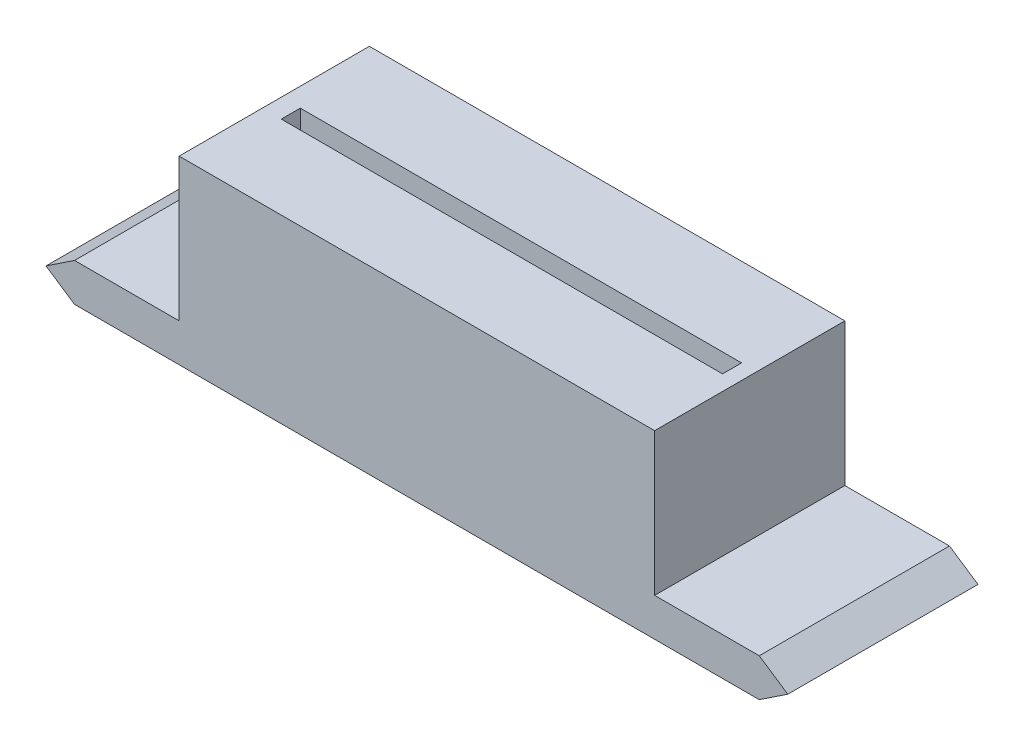
from build123d import *

# Parameters (mm, degrees)
P_IDAT_VYSUNUT_M1_DEPTH  = 10
SKICA2_R                 = 3
ODEBRAT_VYSUNUT_M1_DEPTH = 1
SKICA3_R                 = 2.6
ODEBRAT_VYSUNUT_M2_DEPTH = 7.5
SKICA4_W                 = 23.2
SKICA4_H                 = 1
ODEBRAT_VYSUNUT_M3_DEPTH = 1


with BuildPart() as part:
    # Skica1 → Přidat vysunutím1 (new body)
    with BuildSketch(Plane.XY):
        Polygon((-52.156744291, -7.714704976), (-16.156744291, -7.714704976), (-14.656744291, -6.714704976), (-16.156744291, -5.714704976), (-21.656744291, -5.714704976), (-21.656744291, 1.785295024), (-46.656744291, 1.785295024), (-46.656744291, -5.714704976), (-52.156744291, -5.714704976), (-53.656744291, -6.714704976), align=None)
    extrude(amount=P_IDAT_VYSUNUT_M1_DEPTH)

    # Skica2 → Odebrat vysunutím1 (cut)
    with BuildSketch(Plane(origin=(0, -7.714704976, 0), x_dir=(-1, 0, 0), z_dir=(0, -1, 0))):
        with Locations((43.156744291, -5)):
            Circle(SKICA2_R)
        with Locations((37.146744291, -5)):
            Circle(SKICA2_R)
        with Locations((31.136744291, -5)):
            Circle(SKICA2_R)
        with Locations((25.126744291, -5)):
            Circle(SKICA2_R)
    extrude(amount=-ODEBRAT_VYSUNUT_M1_DEPTH, mode=Mode.SUBTRACT)

    # Skica3 → Odebrat vysunutím2 (cut)
    with BuildSketch(Plane(origin=(0, -6.714704976, 0), x_dir=(-1, 0, 0), z_dir=(0, -1, 0))):
        with Locations((43.156744291, -5)):
            Circle(SKICA3_R)
        with Locations((37.146744291, -5)):
            Circle(SKICA3_R)
        with Locations((31.136744291, -5)):
            Circle(SKICA3_R)
        with Locations((25.126744291, -5)):
            Circle(SKICA3_R)
    extrude(amount=-ODEBRAT_VYSUNUT_M2_DEPTH, mode=Mode.SUBTRACT)

    # Skica4 → Odebrat vysunutím3 (cut)
    with BuildSketch(Plane(origin=(0, 1.785295024, 0), x_dir=(1, 0, 0), z_dir=(0, 1, 0))):
        with Locations((-34.056744291, -5.129927758)):
            Rectangle(SKICA4_W, SKICA4_H)
    extrude(amount=-ODEBRAT_VYSUNUT_M3_DEPTH, mode=Mode.SUBTRACT)


solid = part.part
